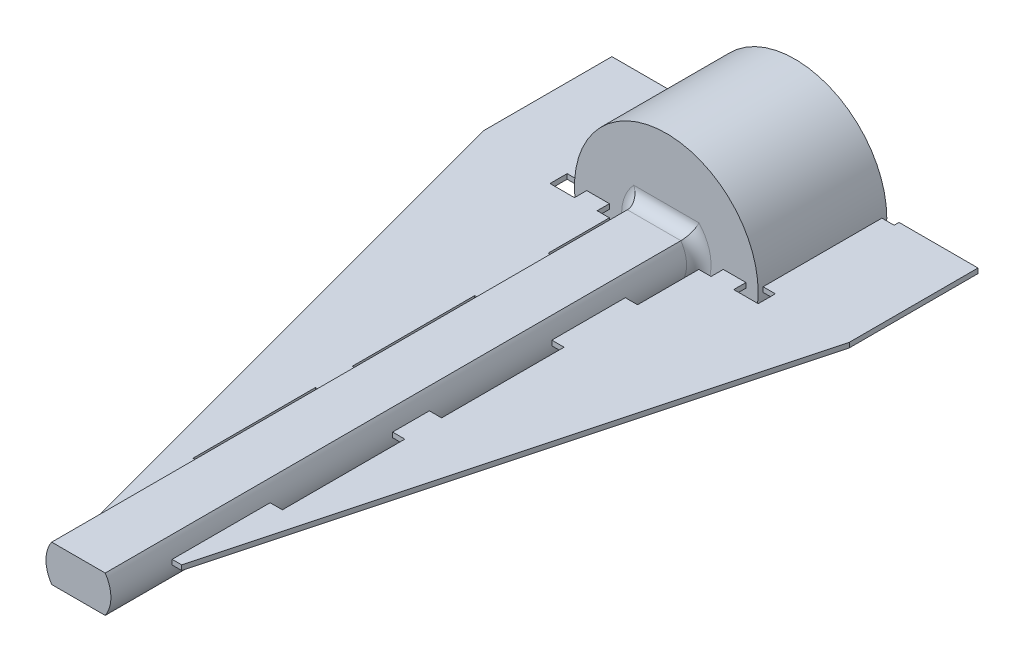
from build123d import *

# Parameters (mm, degrees)
SKETCH2_R                = 7.5
BOSS_EXTRUDE1_DEPTH      = 4
BOSS_EXTRUDE1_DEPTH_BACK = 5.5
SKETCH4_R                = 7.5
BOSS_EXTRUDE2_DEPTH      = 1
BOSS_EXTRUDE3_DEPTH      = 48
FILLET1_R                = 1
BOSS_EXTRUDE6_DEPTH      = 0.2
BOSS_EXTRUDE6_2_DEPTH    = 0.2


with BuildPart() as part:
    # Sketch2 → Boss-Extrude1 (new body, two sides)
    with BuildSketch(Plane.XY) as boss_extrude1_sk:
        with Locations((-178.577921964, 19.246491703)):
            Circle(SKETCH2_R)
        with BuildLine():
            ThreePointArc((-180.964561166, 16.918133172), (-181.154624072, 16.787356328), (-181.28128896, 16.594528692))
            ThreePointArc((-181.28128896, 16.594528692), (-181.41997807, 16.120570829), (-181.458725437, 15.628260596))
            ThreePointArc((-181.458725437, 15.628260596), (-181.203949235, 15.439313513), (-180.936821377, 15.26827369))
            ThreePointArc((-180.936821377, 15.26827369), (-180.490384316, 15.479377161), (-180.096604948, 15.777384768))
            ThreePointArc((-180.096604948, 15.777384768), (-179.961348857, 15.964286563), (-179.906617406, 16.188409207))
            ThreePointArc((-179.906617406, 16.188409207), (-179.860820758, 16.267909453), (-179.769487026, 16.276614146))
            ThreePointArc((-179.769487026, 16.276614146), (-179.651168987, 16.231837357), (-179.531173567, 16.191772177))
            ThreePointArc((-179.531173567, 16.191772177), (-179.465888148, 16.127309504), (-179.480632878, 16.036754465))
            ThreePointArc((-179.480632878, 16.036754465), (-179.57984376, 15.828466942), (-179.593124953, 15.598140867))
            ThreePointArc((-179.593124953, 15.598140867), (-179.476254314, 15.118336763), (-179.263655401, 14.67260991))
            ThreePointArc((-179.263655401, 14.67260991), (-178.948539196, 14.636365038), (-178.631679774, 14.621804135))
            ThreePointArc((-178.631679774, 14.621804135), (-178.350605674, 15.027843634), (-178.158586541, 15.482815477))
            ThreePointArc((-178.158586541, 15.482815477), (-178.134902228, 15.712305225), (-178.199564723, 15.933766853))
            ThreePointArc((-178.199564723, 15.933766853), (-178.199653785, 16.02551441), (-178.1249088, 16.078719761))
            ThreePointArc((-178.1249088, 16.078719761), (-178.000053977, 16.099100944), (-177.876102305, 16.124401191))
            ThreePointArc((-177.876102305, 16.124401191), (-177.787332137, 16.101217588), (-177.754823928, 16.015422258))
            ThreePointArc((-177.754823928, 16.015422258), (-177.736599312, 15.785434531), (-177.632938125, 15.579325702))
            ThreePointArc((-177.632938125, 15.579325702), (-177.29182313, 15.222238479), (-176.884843645, 14.942527158))
            ThreePointArc((-176.884843645, 14.942527158), (-176.59382257, 15.06869628), (-176.312133809, 15.21451588))
            ThreePointArc((-176.312133809, 15.21451588), (-176.271736248, 15.706693451), (-176.332928722, 16.196720191))
            ThreePointArc((-176.332928722, 16.196720191), (-176.427162379, 16.407306299), (-176.593892556, 16.566766447))
            ThreePointArc((-176.593892556, 16.566766447), (-176.639843465, 16.646177632), (-176.601715085, 16.72962731))
            ThreePointArc((-176.601715085, 16.72962731), (-176.503778228, 16.809705343), (-176.409083055, 16.893591835))
            ThreePointArc((-176.409083055, 16.893591835), (-176.320614032, 16.917899331), (-176.249563433, 16.8598525))
            ThreePointArc((-176.249563433, 16.8598525), (-176.118786588, 16.669789594), (-175.925958953, 16.543124706))
            ThreePointArc((-175.925958953, 16.543124706), (-175.45200109, 16.404435596), (-174.959690856, 16.365688229))
            ThreePointArc((-174.959690856, 16.365688229), (-174.770743774, 16.620464432), (-174.599703951, 16.88759229))
            ThreePointArc((-174.599703951, 16.88759229), (-174.810807422, 17.33402935), (-175.108815029, 17.727808718))
            ThreePointArc((-175.108815029, 17.727808718), (-175.295716824, 17.86306481), (-175.519839467, 17.91779626))
            ThreePointArc((-175.519839467, 17.91779626), (-175.599339714, 17.963592909), (-175.608044407, 18.05492664))
            ThreePointArc((-175.608044407, 18.05492664), (-175.563267617, 18.17324468), (-175.523202438, 18.2932401))
            ThreePointArc((-175.523202438, 18.2932401), (-175.458739765, 18.358525519), (-175.368184725, 18.343780789))
            ThreePointArc((-175.368184725, 18.343780789), (-175.159897203, 18.244569907), (-174.929571128, 18.231288713))
            ThreePointArc((-174.929571128, 18.231288713), (-174.449767024, 18.348159352), (-174.004040171, 18.560758265))
            ThreePointArc((-174.004040171, 18.560758265), (-173.967795299, 18.87587447), (-173.953234396, 19.192733892))
            ThreePointArc((-173.953234396, 19.192733892), (-174.359273895, 19.473807993), (-174.814245738, 19.665827125))
            ThreePointArc((-174.814245738, 19.665827125), (-175.043735485, 19.689511439), (-175.265197114, 19.624848944))
            ThreePointArc((-175.265197114, 19.624848944), (-175.356944671, 19.624759881), (-175.410150022, 19.699504867))
            ThreePointArc((-175.410150022, 19.699504867), (-175.430531205, 19.824359689), (-175.455831451, 19.948311361))
            ThreePointArc((-175.455831451, 19.948311361), (-175.432647848, 20.037081529), (-175.346852519, 20.069589738))
            ThreePointArc((-175.346852519, 20.069589738), (-175.116864792, 20.087814355), (-174.910755963, 20.191475542))
            ThreePointArc((-174.910755963, 20.191475542), (-174.553668739, 20.532590536), (-174.273957418, 20.939570022))
            ThreePointArc((-174.273957418, 20.939570022), (-174.400126541, 21.230591097), (-174.54594614, 21.512279857))
            ThreePointArc((-174.54594614, 21.512279857), (-175.038123712, 21.552677419), (-175.528150452, 21.491484944))
            ThreePointArc((-175.528150452, 21.491484944), (-175.73873656, 21.397251288), (-175.898196708, 21.23052111))
            ThreePointArc((-175.898196708, 21.23052111), (-175.977607892, 21.184570201), (-176.061057571, 21.222698582))
            ThreePointArc((-176.061057571, 21.222698582), (-176.141135604, 21.320635439), (-176.225022096, 21.415330612))
            ThreePointArc((-176.225022096, 21.415330612), (-176.249329591, 21.503799634), (-176.191282761, 21.574850234))
            ThreePointArc((-176.191282761, 21.574850234), (-176.001219855, 21.705627078), (-175.874554967, 21.898454714))
            ThreePointArc((-175.874554967, 21.898454714), (-175.735865857, 22.372412576), (-175.69711849, 22.86472281))
            ThreePointArc((-175.69711849, 22.86472281), (-175.951894692, 23.053669893), (-176.21902255, 23.224709716))
            ThreePointArc((-176.21902255, 23.224709716), (-176.665459611, 23.013606245), (-177.059238979, 22.715598637))
            ThreePointArc((-177.059238979, 22.715598637), (-177.19449507, 22.528696843), (-177.249226521, 22.304574199))
            ThreePointArc((-177.249226521, 22.304574199), (-177.295023169, 22.225073952), (-177.386356901, 22.21636926))
            ThreePointArc((-177.386356901, 22.21636926), (-177.50467494, 22.261146049), (-177.62467036, 22.301211229))
            ThreePointArc((-177.62467036, 22.301211229), (-177.68995578, 22.365673902), (-177.67521105, 22.456228941))
            ThreePointArc((-177.67521105, 22.456228941), (-177.576000167, 22.664516463), (-177.562718974, 22.894842539))
            ThreePointArc((-177.562718974, 22.894842539), (-177.679589613, 23.374646643), (-177.892188526, 23.820373495))
            ThreePointArc((-177.892188526, 23.820373495), (-178.207304731, 23.856618368), (-178.524164153, 23.871179271))
            ThreePointArc((-178.524164153, 23.871179271), (-178.805238253, 23.465139771), (-178.997257386, 23.010167929))
            ThreePointArc((-178.997257386, 23.010167929), (-179.0209417, 22.780678181), (-178.956279204, 22.559216553))
            ThreePointArc((-178.956279204, 22.559216553), (-178.956190142, 22.467468995), (-179.030935127, 22.414263644))
            ThreePointArc((-179.030935127, 22.414263644), (-179.15578995, 22.393882462), (-179.279741622, 22.368582215))
            ThreePointArc((-179.279741622, 22.368582215), (-179.36851179, 22.391765818), (-179.401019999, 22.477561148))
            ThreePointArc((-179.401019999, 22.477561148), (-179.419244616, 22.707548874), (-179.522905803, 22.913657703))
            ThreePointArc((-179.522905803, 22.913657703), (-179.864020797, 23.270744927), (-180.271000283, 23.550456248))
            ThreePointArc((-180.271000283, 23.550456248), (-180.562021357, 23.424287126), (-180.843710118, 23.278467526))
            ThreePointArc((-180.843710118, 23.278467526), (-180.88410768, 22.786289955), (-180.822915205, 22.296263215))
            ThreePointArc((-180.822915205, 22.296263215), (-180.728681548, 22.085677107), (-180.561951371, 21.926216958))
            ThreePointArc((-180.561951371, 21.926216958), (-180.516000462, 21.846805774), (-180.554128842, 21.763356096))
            ThreePointArc((-180.554128842, 21.763356096), (-180.6520657, 21.683278063), (-180.746760873, 21.59939157))
            ThreePointArc((-180.746760873, 21.59939157), (-180.835229895, 21.575084075), (-180.906280494, 21.633130906))
            ThreePointArc((-180.906280494, 21.633130906), (-181.037057339, 21.823193811), (-181.229884975, 21.9498587))
            ThreePointArc((-181.229884975, 21.9498587), (-181.703842837, 22.08854781), (-182.196153071, 22.127295177))
            ThreePointArc((-182.196153071, 22.127295177), (-182.385100154, 21.872518974), (-182.556139976, 21.605391116))
            ThreePointArc((-182.556139976, 21.605391116), (-182.345036505, 21.158954055), (-182.047028898, 20.765174687))
            ThreePointArc((-182.047028898, 20.765174687), (-181.860127103, 20.629918596), (-181.63600446, 20.575187146))
            ThreePointArc((-181.63600446, 20.575187146), (-181.556504213, 20.529390497), (-181.54779952, 20.438056766))
            ThreePointArc((-181.54779952, 20.438056766), (-181.59257631, 20.319738726), (-181.632641489, 20.199743306))
            ThreePointArc((-181.632641489, 20.199743306), (-181.697104162, 20.134457887), (-181.787659202, 20.149202617))
            ThreePointArc((-181.787659202, 20.149202617), (-181.995946724, 20.248413499), (-182.226272799, 20.261694692))
            ThreePointArc((-182.226272799, 20.261694692), (-182.706076904, 20.144824054), (-183.151803756, 19.932225141))
            ThreePointArc((-183.151803756, 19.932225141), (-183.188048629, 19.617108936), (-183.202609531, 19.300249514))
            ThreePointArc((-183.202609531, 19.300249514), (-182.796570032, 19.019175413), (-182.34159819, 18.82715628))
            ThreePointArc((-182.34159819, 18.82715628), (-182.112108442, 18.803471967), (-181.890646814, 18.868134462))
            ThreePointArc((-181.890646814, 18.868134462), (-181.798899256, 18.868223525), (-181.745693905, 18.793478539))
            ThreePointArc((-181.745693905, 18.793478539), (-181.725312723, 18.668623716), (-181.700012476, 18.544672045))
            ThreePointArc((-181.700012476, 18.544672045), (-181.723196079, 18.455901876), (-181.808991408, 18.423393667))
            ThreePointArc((-181.808991408, 18.423393667), (-182.038979135, 18.405169051), (-182.245087964, 18.301507864))
            ThreePointArc((-182.245087964, 18.301507864), (-182.602175188, 17.96039287), (-182.881886509, 17.553413384))
            ThreePointArc((-182.881886509, 17.553413384), (-182.755717387, 17.262392309), (-182.609897787, 16.980703549))
            ThreePointArc((-182.609897787, 16.980703549), (-182.117720216, 16.940305987), (-181.627693476, 17.001498461))
            ThreePointArc((-181.627693476, 17.001498461), (-181.417107367, 17.095732118), (-181.257647219, 17.262462296))
            ThreePointArc((-181.257647219, 17.262462296), (-181.178236035, 17.308413205), (-181.094786356, 17.270284824))
            ThreePointArc((-181.094786356, 17.270284824), (-181.014708323, 17.172347967), (-180.930821831, 17.077652794))
            ThreePointArc((-180.930821831, 17.077652794), (-180.906514336, 16.989183772), (-180.964561166, 16.918133172))
        make_face(mode=Mode.SUBTRACT)
    extrude(amount=BOSS_EXTRUDE1_DEPTH)
    extrude(boss_extrude1_sk.sketch, amount=-BOSS_EXTRUDE1_DEPTH_BACK)

    # Sketch4 → Boss-Extrude2 (add)
    with BuildSketch(Plane.XY.offset(4)):
        with Locations((-178.577921964, 19.246491703)):
            Circle(SKETCH4_R)
    extrude(amount=BOSS_EXTRUDE2_DEPTH)

    # Sketch6 → Boss-Extrude3 (add)
    with BuildSketch(Plane.XY.offset(5)):
        with BuildLine():
            Line((-180.762527191, 20.746491703), (-176.393316736, 20.746491703))
            ThreePointArc((-176.393316736, 20.746491703), (-175.927921964, 19.246491703), (-176.393316736, 17.746491703))
            Line((-176.393316736, 17.746491703), (-180.762527191, 17.746491703))
            ThreePointArc((-180.762527191, 17.746491703), (-181.227921964, 19.246491703), (-180.762527191, 20.746491703))
        make_face()
    extrude(amount=BOSS_EXTRUDE3_DEPTH)

    # Fillet1
    fillet1_edges = [part.edges().sort_by_distance(p)[0] for p in [
        (-175.927921964, 19.246491703, 5),
        (-178.577921964, 20.746491703, 5),
        (-181.227921964, 19.246491703, 5),
        (-178.577921964, 17.746491703, 5),
    ]]
    fillet(fillet1_edges, radius=FILLET1_R)


with BuildPart() as body_2:
    # Sketch7 → Boss-Extrude6 (new body, symmetric)
    with BuildSketch(Plane(origin=(0, 19.246491703, 0), x_dir=(1, 0, 0), z_dir=(0, 1, 0))):
        Polygon((-182.227921964, -6), (-182.227921964, -11), (-181.227921964, -11), (-181.227921964, -17), (-182.227921964, -17), (-182.227921964, -27), (-181.227921964, -27), (-181.227921964, -30), (-182.227921964, -30), (-182.227921964, -40), (-181.227921964, -40), (-181.227921964, -48), (-182.002348878, -48), (-193.524164153, -5), (-193.524164153, 5.5), (-187.077921964, 5.5), (-187.077921964, 5.1), (-186.077921964, 5.1), (-186.077921964, -4.6), (-187.077921964, -4.6), (-187.077921964, -6), (-185.077921964, -6), (-185.077921964, -5), (-183.227921964, -5), (-183.227921964, -6), align=None)
    extrude(amount=BOSS_EXTRUDE6_DEPTH, both=True)


with BuildPart() as body_3:
    # Sketch7 → Boss-Extrude6 2 (new body, symmetric)
    with BuildSketch(Plane(origin=(0, 19.246491703, 0), x_dir=(1, 0, 0), z_dir=(0, 1, 0))):
        Polygon((-175.153495049, -48), (-175.927921964, -48), (-175.927921964, -40), (-174.927921964, -40), (-174.927921964, -30), (-175.927921964, -30), (-175.927921964, -27), (-174.927921964, -27), (-174.927921964, -17), (-175.927921964, -17), (-175.927921964, -11), (-174.927921964, -11), (-174.927921964, -6), (-173.927921964, -6), (-173.927921964, -5), (-172.077921964, -5), (-172.077921964, -6), (-170.077921964, -6), (-170.077921964, -4.6), (-171.077921964, -4.6), (-171.077921964, 5.1), (-170.077921964, 5.1), (-170.077921964, 5.5), (-163.631679774, 5.5), (-163.631679774, -5), align=None)
    extrude(amount=BOSS_EXTRUDE6_2_DEPTH, both=True)


solid = Compound([part.part, body_2.part, body_3.part])
